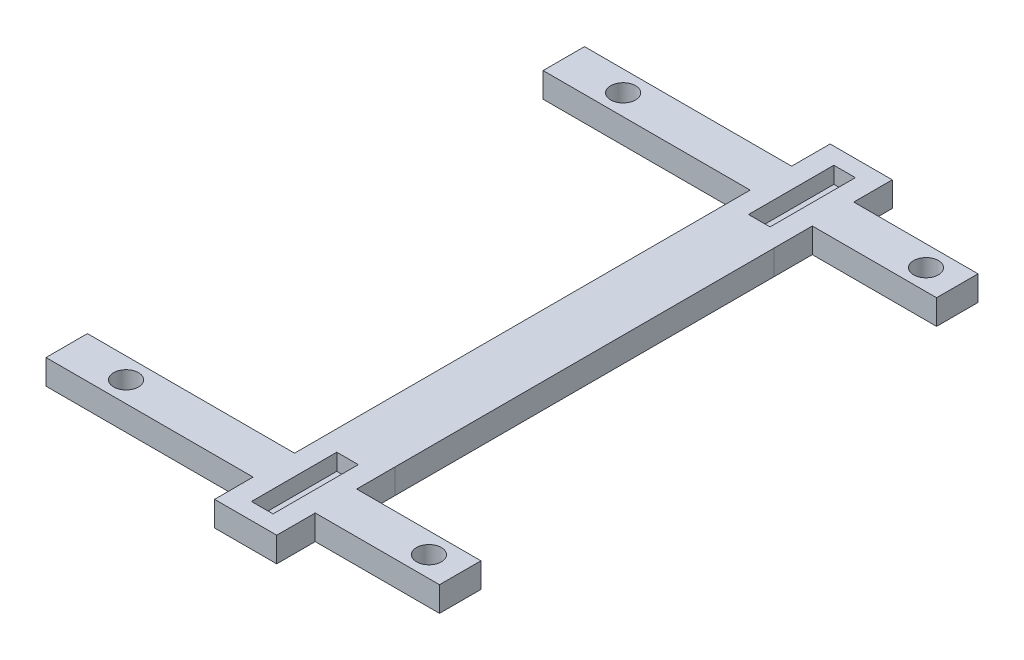
from build123d import *

# Parameters (mm, degrees)
SKETCH1_4_R         = 3
SKETCH1_4_W         = 5.2
SKETCH1_4_H         = 20.6
BOSS_EXTRUDE2_DEPTH = 4
BOSS_EXTRUDE3_START = -2
SKETCH1_5_R         = 3
SKETCH1_5_R_2       = 1
BOSS_EXTRUDE3_DEPTH = 2


with BuildPart() as part:
    # Sketch1_4 → Boss-Extrude2 (new body)
    with BuildSketch(Plane(origin=(0, 0, 0), x_dir=(1, 0, 0), z_dir=(0, 1, 0))):
        Polygon((-61.058774723, -57.925766481), (-61.058774723, -67.225766481), (-46.058774723, -67.225766481), (-46.058774723, -57.925766481), (-16.058774723, -57.925766481), (-16.058774723, -47.925766481), (-46.058065355, -47.925766481), (-46.058065355, -38.625766481), (-46.058774723, 52.774233519), (-46.058774723, 62.074233519), (-16.058774723, 62.074233519), (-16.058774723, 72.074233519), (-46.058065355, 72.074233519), (-46.058065355, 81.374233519), (-61.058065355, 81.374233519), (-61.058065355, 72.074233519), (-111.058065355, 72.074233519), (-111.058065355, 62.074233519), (-61.058774723, 62.074233519), (-61.058774723, 52.774233519), (-61.058065355, -38.625766481), (-61.058065355, -47.925766481), (-111.058065355, -47.925766481), (-111.058065355, -57.925766481), align=None)
        with Locations((-96.731187499, -52.925766481)):
            Circle(SKETCH1_4_R, mode=Mode.SUBTRACT)
        with Locations((-53.558065355, -52.925766481)):
            Rectangle(SKETCH1_4_W, SKETCH1_4_H, mode=Mode.SUBTRACT)
        with Locations((-23.608327945, -52.925766481)):
            Circle(SKETCH1_4_R, mode=Mode.SUBTRACT)
        with Locations((-23.608327945, 67.074233519)):
            Circle(SKETCH1_4_R, mode=Mode.SUBTRACT)
        with Locations((-96.731187499, 67.074233519)):
            Circle(SKETCH1_4_R, mode=Mode.SUBTRACT)
        with Locations((-53.558065355, 67.074233519)):
            Rectangle(SKETCH1_4_W, SKETCH1_4_H, mode=Mode.SUBTRACT)
    extrude(amount=BOSS_EXTRUDE2_DEPTH)

    # Sketch1_5 → Boss-Extrude3 (add)
    with BuildSketch(Plane(origin=(0, 0, 0), x_dir=(1, 0, 0), z_dir=(0, 1, 0)).offset(BOSS_EXTRUDE3_START)):
        Polygon((-61.058774723, -57.925766481), (-61.058774723, -67.225766481), (-46.058774723, -67.225766481), (-46.058774723, -57.925766481), (-16.058774723, -57.925766481), (-16.058774723, -47.925766481), (-46.058065355, -47.925766481), (-46.058065355, -38.625766481), (-46.058774723, 52.774233519), (-46.058774723, 62.074233519), (-16.058774723, 62.074233519), (-16.058774723, 72.074233519), (-46.058065355, 72.074233519), (-46.058065355, 81.374233519), (-61.058065355, 81.374233519), (-61.058065355, 72.074233519), (-111.058065355, 72.074233519), (-111.058065355, 62.074233519), (-61.058774723, 62.074233519), (-61.058774723, 52.774233519), (-61.058065355, -38.625766481), (-61.058065355, -47.925766481), (-111.058065355, -47.925766481), (-111.058065355, -57.925766481), align=None)
        with Locations((-96.731187499, -52.925766481)):
            Circle(SKETCH1_5_R, mode=Mode.SUBTRACT)
        with Locations((-23.608327945, -52.925766481)):
            Circle(SKETCH1_5_R, mode=Mode.SUBTRACT)
        with Locations((-53.558065355, -58.925766481)):
            Circle(SKETCH1_5_R_2, mode=Mode.SUBTRACT)
        with Locations((-53.558065355, -46.925766481)):
            Circle(SKETCH1_5_R_2, mode=Mode.SUBTRACT)
        with Locations((-23.608327945, 67.074233519)):
            Circle(SKETCH1_5_R, mode=Mode.SUBTRACT)
        with Locations((-96.731187499, 67.074233519)):
            Circle(SKETCH1_5_R, mode=Mode.SUBTRACT)
        with Locations((-53.558065355, 61.074233519)):
            Circle(SKETCH1_5_R_2, mode=Mode.SUBTRACT)
        with Locations((-53.558065355, 73.074233519)):
            Circle(SKETCH1_5_R_2, mode=Mode.SUBTRACT)
    extrude(amount=BOSS_EXTRUDE3_DEPTH)


solid = part.part
